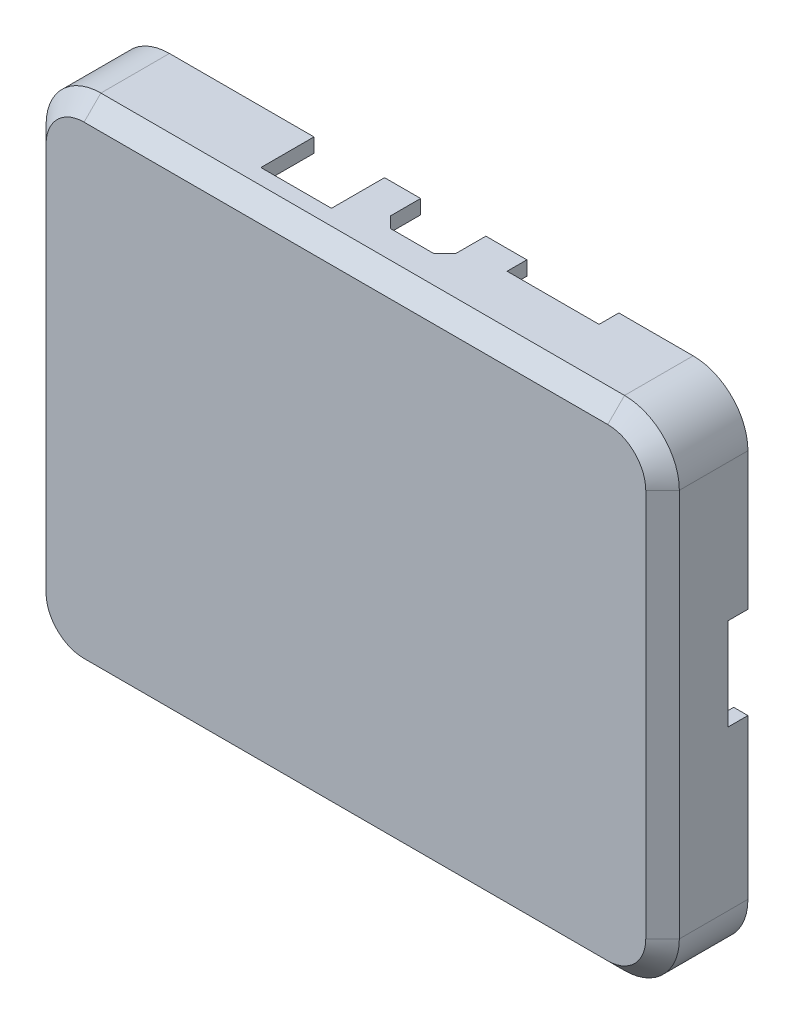
from build123d import *

# Parameters (mm, degrees)
SKETCH_1_W                      = 89
SKETCH_1_H                      = 70
EXTRUDE_1_DEPTH                 = 12
FILLET_1_R                      = 7.7
CHAMFER_1_SIZE                  = 2.36
SHELL_1_T                       = -2
CUT_EXTRUDE_1_REACH             = 72
SKETCH_2_W                      = 9.92
SKETCH_2_H                      = 7.46
SKETCH_2_W_2                    = 12.93
SKETCH_2_H_2                    = 2.78
CUT_EXTRUDE_2_REACH             = 91
SKETCH_3_W                      = 2.78
SKETCH_3_H                      = 12.93
SKETCH_3_W_2                    = 6.7
SKETCH_3_H_2                    = 17
CUT_EXTRUDE_2_DIRECTION_2_DEPTH = 1
CUT_EXTRUDE_3_REACH             = 91
SKETCH_4_W                      = 2.78
SKETCH_4_H                      = 12.93
SKETCH_5_R                      = 4.5
EXTRUDE_2_DEPTH                 = 10
SKETCH_6_R                      = 1.45
CUT_EXTRUDE_4_DEPTH             = 10.9


with BuildPart() as part:
    # 草圖1 → 填料-伸長1 (new body)
    with BuildSketch(Plane.XY):
        Rectangle(SKETCH_1_W, SKETCH_1_H)
    extrude(amount=EXTRUDE_1_DEPTH)

    # 圓角1
    fillet_1_edges = [part.edges().sort_by_distance(p)[0] for p in [
        (44.5, -35, 6),
        (-44.5, -35, 6),
        (-44.5, 35, 6),
        (44.5, 35, 6),
    ]]
    fillet(fillet_1_edges, radius=FILLET_1_R)

    # 導角1
    chamfer_1_edges = [part.edges().sort_by_distance(p)[0] for p in [
        (44.5, 0, 12),
        (0, -35, 12),
        (0, 35, 12),
        (-44.5, 0, 12),
        (-42.244722215, 32.744722215, 12),
        (-42.244722215, -32.744722215, 12),
        (42.244722215, 32.744722215, 12),
        (42.244722215, -32.744722215, 12),
    ]]
    chamfer(chamfer_1_edges, length=CHAMFER_1_SIZE)

    # 薄殼1
    shell_1_openings = [part.faces().sort_by_distance(p)[0] for p in [
        (0, 0, 0),
    ]]
    offset(amount=SHELL_1_T, openings=shell_1_openings, kind=Kind.INTERSECTION)

    # 草圖2 → 除料-伸長1 (cut, up to next)
    with BuildSketch(Plane(origin=(0, 35, 0), x_dir=(1, 0, 0), z_dir=(0, 1, 0)), mode=Mode.PRIVATE) as cut_extrude_1_sk1:
        with Locations((-11.53, -3.73)):
            Rectangle(SKETCH_2_W, SKETCH_2_H)
    cut_extrude_1_tool1 = extrude(cut_extrude_1_sk1.sketch, amount=-CUT_EXTRUDE_1_REACH, mode=Mode.PRIVATE) & part.part
    add(cut_extrude_1_tool1.solids().sort_by_distance((-11.53, 35, 3.73))[0], mode=Mode.SUBTRACT)
    # 草圖2 → 除料-伸長1 (cut, up to next)
    with BuildSketch(Plane(origin=(0, 35, 0), x_dir=(1, 0, 0), z_dir=(0, 1, 0)), mode=Mode.PRIVATE) as cut_extrude_1_sk2:
        Polygon((-1.5, 0), (-1.5, -4.23), (0.05, -5.777126368), (6.12, -5.777126368), (7.67, -4.23), (7.67, 0), align=None)
    cut_extrude_1_tool2 = extrude(cut_extrude_1_sk2.sketch, amount=-CUT_EXTRUDE_1_REACH, mode=Mode.PRIVATE) & part.part
    add(cut_extrude_1_tool2.solids().sort_by_distance((3.085, 35, 2.77606))[0], mode=Mode.SUBTRACT)
    # 草圖2 → 除料-伸長1 (cut, up to next)
    with BuildSketch(Plane(origin=(0, 35, 0), x_dir=(1, 0, 0), z_dir=(0, 1, 0)), mode=Mode.PRIVATE) as cut_extrude_1_sk3:
        with Locations((19.895, -1.39)):
            Rectangle(SKETCH_2_W_2, SKETCH_2_H_2)
    cut_extrude_1_tool3 = extrude(cut_extrude_1_sk3.sketch, amount=-CUT_EXTRUDE_1_REACH, mode=Mode.PRIVATE) & part.part
    add(cut_extrude_1_tool3.solids().sort_by_distance((19.895, 35, 1.39))[0], mode=Mode.SUBTRACT)

    # 草圖3 → 除料-伸長2 (cut, up to next)
    with BuildSketch(Plane.ZY.offset(44.5), mode=Mode.PRIVATE) as cut_extrude_2_sk1:
        with Locations((1.39, 2.965)):
            Rectangle(SKETCH_3_W, SKETCH_3_H)
    cut_extrude_2_tool1 = extrude(cut_extrude_2_sk1.sketch, amount=-CUT_EXTRUDE_2_REACH, mode=Mode.PRIVATE) & part.part
    add(cut_extrude_2_tool1.solids().sort_by_distance((-44.5, 2.965, 1.39))[0], mode=Mode.SUBTRACT)
    # 草圖3 → 除料-伸長2 (cut, up to next)
    with BuildSketch(Plane.ZY.offset(44.5), mode=Mode.PRIVATE) as cut_extrude_2_sk2:
        with Locations((3.35, -15)):
            Rectangle(SKETCH_3_W_2, SKETCH_3_H_2)
    cut_extrude_2_tool2 = extrude(cut_extrude_2_sk2.sketch, amount=-CUT_EXTRUDE_2_REACH, mode=Mode.PRIVATE) & part.part
    add(cut_extrude_2_tool2.solids().sort_by_distance((-44.5, -15, 3.35))[0], mode=Mode.SUBTRACT)

    # 草圖3 → 除料-伸長2 direction 2 (cut)
    with BuildSketch(Plane.ZY.offset(44.5)):
        with Locations((1.39, 2.965)):
            Rectangle(SKETCH_3_W, SKETCH_3_H)
        with Locations((3.35, -15)):
            Rectangle(SKETCH_3_W_2, SKETCH_3_H_2)
    extrude(amount=CUT_EXTRUDE_2_DIRECTION_2_DEPTH, mode=Mode.SUBTRACT)

    # 草圖4 → 除料-伸長3 (cut, up to next)
    with BuildSketch(Plane(origin=(44.5, 0, 0), x_dir=(0, 0, -1), z_dir=(1, 0, 0)), mode=Mode.PRIVATE) as cut_extrude_3_sk1:
        with Locations((-1.39, 1.535)):
            Rectangle(SKETCH_4_W, SKETCH_4_H)
    cut_extrude_3_tool1 = extrude(cut_extrude_3_sk1.sketch, amount=-CUT_EXTRUDE_3_REACH, mode=Mode.PRIVATE) & part.part
    add(cut_extrude_3_tool1.solids().sort_by_distance((44.5, 1.535, 1.39))[0], mode=Mode.SUBTRACT)

    # 草圖5 → 填料-伸長2 (add)
    with BuildSketch(Plane(origin=(0, 0, 10), x_dir=(-1, 0, 0), z_dir=(0, 0, -1))):
        with Locations((-35.311572875, 25.811572875)):
            Circle(SKETCH_5_R)
        with Locations((35.311572875, 25.811572875)):
            Circle(SKETCH_5_R)
        with Locations((35.311572875, -25.811572875)):
            Circle(SKETCH_5_R)
        with Locations((-35.311572875, -25.811572875)):
            Circle(SKETCH_5_R)
    extrude(amount=EXTRUDE_2_DEPTH)

    # 草圖6 → 除料-伸長4 (cut)
    with BuildSketch(Plane(origin=(0, 0, 0), x_dir=(-1, 0, 0), z_dir=(0, 0, -1))):
        with Locations((-35.311572875, 25.811572875)):
            Circle(SKETCH_6_R)
        with Locations((35.311572875, 25.811572875)):
            Circle(SKETCH_6_R)
        with Locations((35.311572875, -25.811572875)):
            Circle(SKETCH_6_R)
        with Locations((-35.311572875, -25.811572875)):
            Circle(SKETCH_6_R)
    extrude(amount=-CUT_EXTRUDE_4_DEPTH, mode=Mode.SUBTRACT)


solid = part.part
